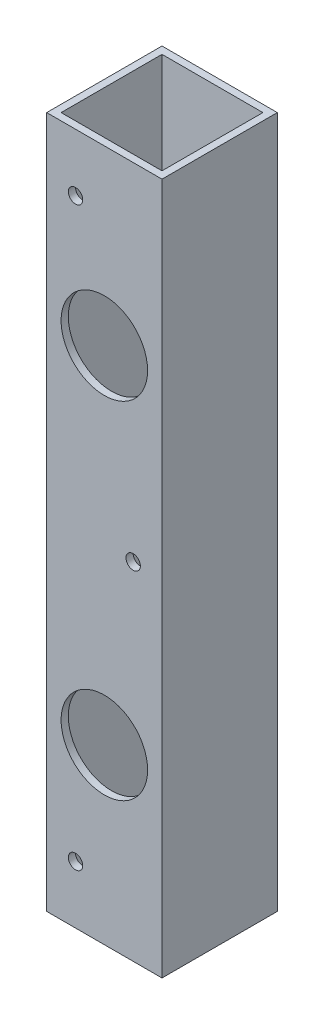
from build123d import *

# Parameters (mm, degrees)
SKETCH1_W           = 25.4
SKETCH1_H           = 25.4
SKETCH1_W_2         = 22.225
SKETCH1_H_2         = 22.225
EXTRUDE_THIN1_DEPTH = 152.4
CUT_EXTRUDE1_REACH  = 27.4
SKETCH2_R           = 9.525
SKETCH2_R_2         = 1.5875
SKETCH4_R           = 3.3782
CUT_EXTRUDE2_DEPTH  = 2.5875


with BuildPart() as part:
    # Sketch1 → Extrude-Thin1 (new body)
    with BuildSketch(Plane(origin=(0, 0, 0), x_dir=(1, 0, 0), z_dir=(0, 1, 0))):
        Rectangle(SKETCH1_W, SKETCH1_H)
        Rectangle(SKETCH1_W_2, SKETCH1_H_2, mode=Mode.SUBTRACT)
    extrude(amount=EXTRUDE_THIN1_DEPTH)

    # Sketch2 → Cut-Extrude1 (cut, up to next)
    with BuildSketch(Plane.XY.offset(12.7), mode=Mode.PRIVATE) as cut_extrude1_sk1:
        with Locations((0, 114.3)):
            Circle(SKETCH2_R)
    cut_extrude1_tool1 = extrude(cut_extrude1_sk1.sketch, amount=-CUT_EXTRUDE1_REACH, mode=Mode.PRIVATE) & part.part
    add(cut_extrude1_tool1.solids().sort_by_distance((0, 114.3, 12.7))[0], mode=Mode.SUBTRACT)
    # Sketch2 → Cut-Extrude1 (cut, up to next)
    with BuildSketch(Plane.XY.offset(12.7), mode=Mode.PRIVATE) as cut_extrude1_sk2:
        with Locations((0, 38.1)):
            Circle(SKETCH2_R)
    cut_extrude1_tool2 = extrude(cut_extrude1_sk2.sketch, amount=-CUT_EXTRUDE1_REACH, mode=Mode.PRIVATE) & part.part
    add(cut_extrude1_tool2.solids().sort_by_distance((0, 38.1, 12.7))[0], mode=Mode.SUBTRACT)
    # Sketch2 → Cut-Extrude1 (cut, up to next)
    with BuildSketch(Plane.XY.offset(12.7), mode=Mode.PRIVATE) as cut_extrude1_sk3:
        with Locations((-6.35, 139.7)):
            Circle(SKETCH2_R_2)
    cut_extrude1_tool3 = extrude(cut_extrude1_sk3.sketch, amount=-CUT_EXTRUDE1_REACH, mode=Mode.PRIVATE) & part.part
    add(cut_extrude1_tool3.solids().sort_by_distance((-6.35, 139.7, 12.7))[0], mode=Mode.SUBTRACT)
    # Sketch2 → Cut-Extrude1 (cut, up to next)
    with BuildSketch(Plane.XY.offset(12.7), mode=Mode.PRIVATE) as cut_extrude1_sk4:
        with Locations((6.35, 76.2)):
            Circle(SKETCH2_R_2)
    cut_extrude1_tool4 = extrude(cut_extrude1_sk4.sketch, amount=-CUT_EXTRUDE1_REACH, mode=Mode.PRIVATE) & part.part
    add(cut_extrude1_tool4.solids().sort_by_distance((6.35, 76.2, 12.7))[0], mode=Mode.SUBTRACT)
    # Sketch2 → Cut-Extrude1 (cut, up to next)
    with BuildSketch(Plane.XY.offset(12.7), mode=Mode.PRIVATE) as cut_extrude1_sk5:
        with Locations((-6.35, 12.7)):
            Circle(SKETCH2_R_2)
    cut_extrude1_tool5 = extrude(cut_extrude1_sk5.sketch, amount=-CUT_EXTRUDE1_REACH, mode=Mode.PRIVATE) & part.part
    add(cut_extrude1_tool5.solids().sort_by_distance((-6.35, 12.7, 12.7))[0], mode=Mode.SUBTRACT)

    # Sketch4 → Cut-Extrude2 (cut, through all)
    with BuildSketch(Plane.XY.offset(-11.1125)):
        with Locations((0, 114.3)):
            Circle(SKETCH4_R)
        with Locations((0, 38.1)):
            Circle(SKETCH4_R)
    extrude(amount=-CUT_EXTRUDE2_DEPTH, mode=Mode.SUBTRACT)


solid = part.part
